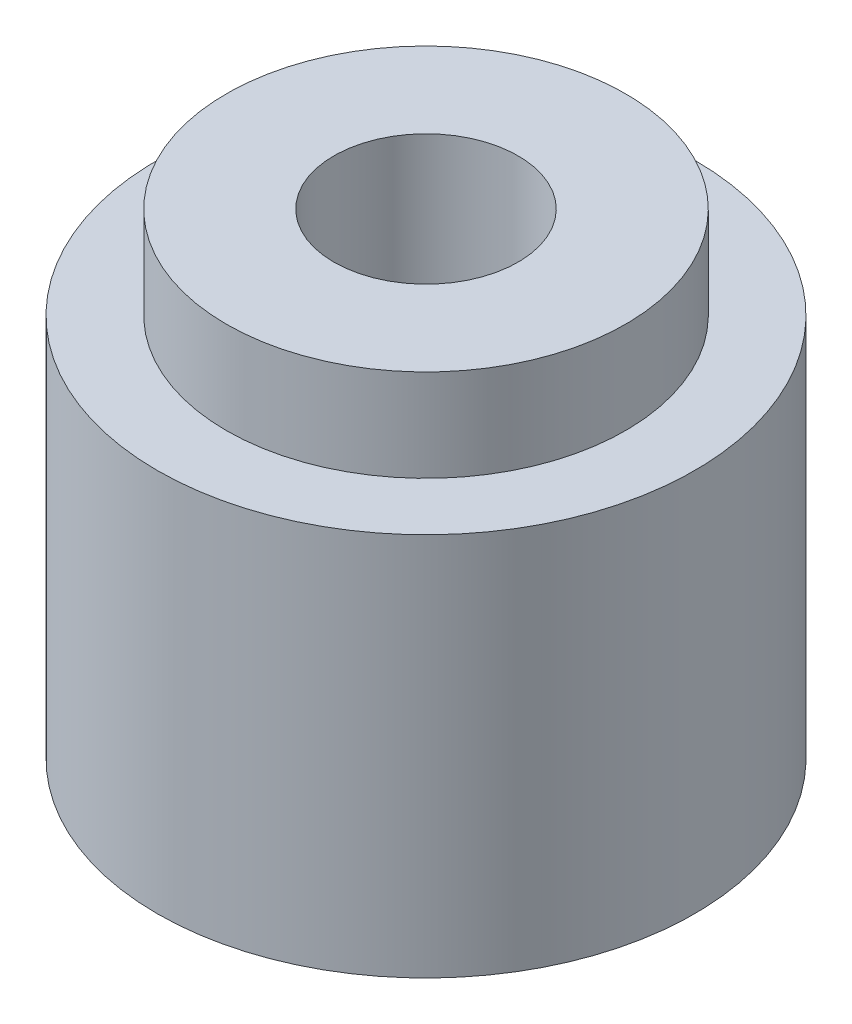
from build123d import *

# Parameters (mm, degrees)
SKETCH1_R           = 17.5
BOSS_EXTRUDE1_DEPTH = 25
SKETCH2_R           = 13
BOSS_EXTRUDE2_DEPTH = 6
SKETCH3_R           = 6
CUT_EXTRUDE1_DEPTH  = 32


with BuildPart() as part:
    # Sketch1 → Boss-Extrude1 (new body)
    with BuildSketch(Plane(origin=(0, 0, 0), x_dir=(1, 0, 0), z_dir=(0, 1, 0))):
        Circle(SKETCH1_R)
    extrude(amount=BOSS_EXTRUDE1_DEPTH)

    # Sketch2 → Boss-Extrude2 (add)
    with BuildSketch(Plane(origin=(0, 25, 0), x_dir=(1, 0, 0), z_dir=(0, 1, 0))):
        Circle(SKETCH2_R)
    extrude(amount=BOSS_EXTRUDE2_DEPTH)

    # Sketch3 → Cut-Extrude1 (cut, through all)
    with BuildSketch(Plane(origin=(0, 31, 0), x_dir=(1, 0, 0), z_dir=(0, 1, 0))):
        Circle(SKETCH3_R)
    extrude(amount=-CUT_EXTRUDE1_DEPTH, mode=Mode.SUBTRACT)


solid = part.part
